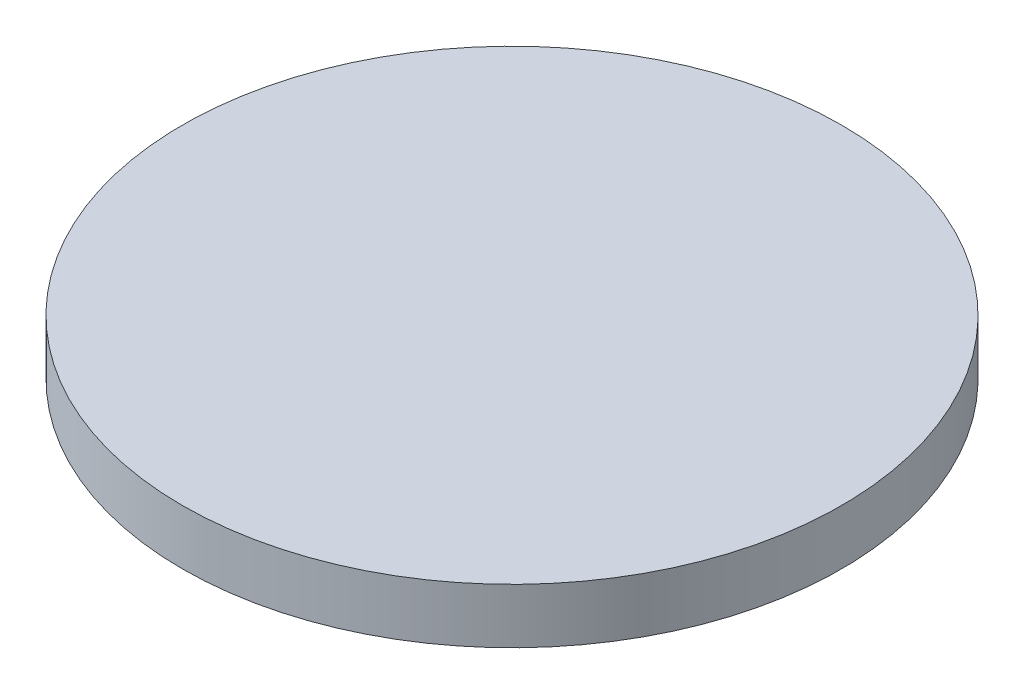
from build123d import *

# Parameters (mm, degrees)
SKETCH1_R           = 6
BOSS_EXTRUDE1_DEPTH = 1


with BuildPart() as part:
    # Sketch1 → Boss-Extrude1 (new body)
    with BuildSketch(Plane(origin=(0, 0, 0), x_dir=(1, 0, 0), z_dir=(0, 1, 0))):
        Circle(SKETCH1_R)
    extrude(amount=BOSS_EXTRUDE1_DEPTH)


solid = part.part
